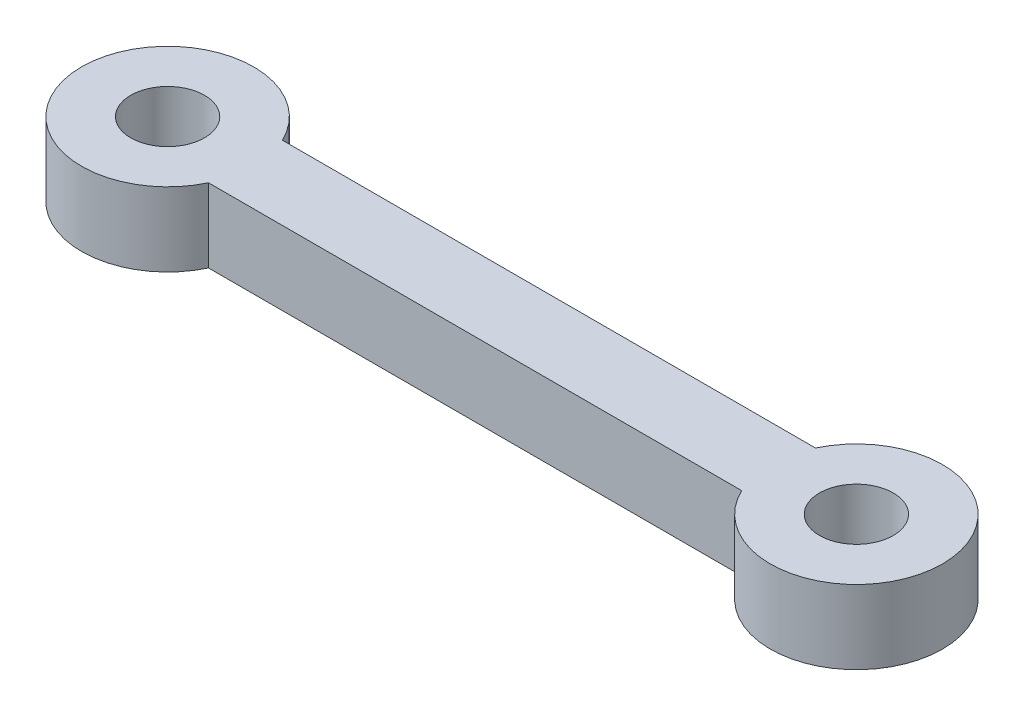
from build123d import *

# Parameters (mm, degrees)
BOSS_EXTRUDE1_DEPTH = 3
SKETCH2_R           = 1.5
CUT_EXTRUDE1_DEPTH  = 3


with BuildPart() as part:
    # Sketch1 → Boss-Extrude1 (new body)
    with BuildSketch(Plane(origin=(0, 0, 0), x_dir=(1, 0, 0), z_dir=(0, 1, 0))):
        with BuildLine():
            Line((3.16227766, 1.5), (24.83772234, 1.5))
            ThreePointArc((24.83772234, 1.5), (31.5, 0), (24.83772234, -1.5))
            Line((24.83772234, -1.5), (3.16227766, -1.5))
            ThreePointArc((3.16227766, -1.5), (-3.5, 0), (3.16227766, 1.5))
        make_face()
    extrude(amount=BOSS_EXTRUDE1_DEPTH)

    # Sketch2 → Cut-Extrude1 (cut)
    with BuildSketch(Plane(origin=(0, 3, 0), x_dir=(1, 0, 0), z_dir=(0, 1, 0))):
        Circle(SKETCH2_R)
        with Locations((28, 0)):
            Circle(SKETCH2_R)
    extrude(amount=-CUT_EXTRUDE1_DEPTH, mode=Mode.SUBTRACT)


solid = part.part
